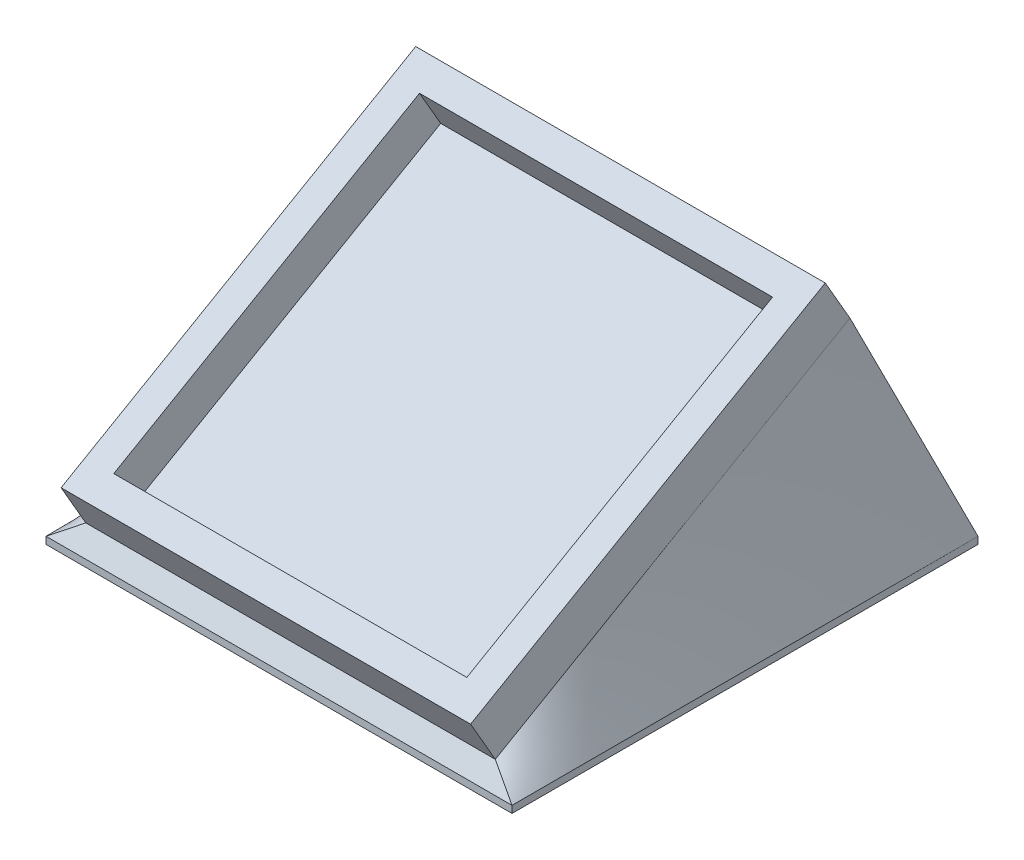
from build123d import *

# Parameters (mm, degrees)
SKETCH1_W             = 36.83
SKETCH1_H             = 36.83
BOSS_EXTRUDE1_DEPTH   = 0.635
SKETCH2_W             = 36.83
SKETCH2_H             = 36.83
SKETCH2_W_2           = 31.75
SKETCH2_H_2           = 31.75
BOSS_EXTRUDE2_DEPTH   = 3.81
SKETCH3_W             = 41.91
SKETCH3_H             = 41.91
BOSS_EXTRUDE3_DEPTH   = 0.635
BODY_MOVE_COPY2_ANGLE = 30
CUT_EXTRUDE1_DEPTH    = 0.635


with BuildPart() as part:
    # Sketch1 → Boss-Extrude1 (new body)
    with BuildSketch(Plane(origin=(0, 0, 0), x_dir=(1, 0, 0), z_dir=(0, 1, 0))):
        with Locations((-3.873751075, -5.413720286)):
            Rectangle(SKETCH1_W, SKETCH1_H)
    extrude(amount=BOSS_EXTRUDE1_DEPTH)

    # Sketch2 → Boss-Extrude2 (add)
    with BuildSketch(Plane(origin=(0, 0.635, 0), x_dir=(1, 0, 0), z_dir=(0, 1, 0))):
        with Locations((-3.873751075, -5.413720286)):
            Rectangle(SKETCH2_W, SKETCH2_H)
        with Locations((-3.873751075, -5.413720286)):
            Rectangle(SKETCH2_W_2, SKETCH2_H_2, mode=Mode.SUBTRACT)
    extrude(amount=BOSS_EXTRUDE2_DEPTH)


with BuildPart() as part_1:
    # Body-Move/Copy1: moved
    add(part.part.moved(Location((0, 12.7, 0))))


with BuildPart() as body_2:
    # Sketch3 → Boss-Extrude3 (new body)
    with BuildSketch(Plane(origin=(0, 0, 0), x_dir=(1, 0, 0), z_dir=(0, 1, 0))):
        with Locations((-3.873751075, -5.413720286)):
            Rectangle(SKETCH3_W, SKETCH3_H)
    extrude(amount=BOSS_EXTRUDE3_DEPTH)


with BuildPart() as part_2:
    # Body-Move/Copy2: moved
    add(part_1.part.moved(Location((0, 0, 0))).rotate(Axis((0, 4.7625, 5.413720286), (1, 0, 0)), BODY_MOVE_COPY2_ANGLE))


    add(body_2.part)  # loft1 joins it to this body
    # loft from a face of the part (loft1)
    loft([part_2.faces().sort_by_distance((-3.873751075, 11.636576643, 9.382470286))[0], part_2.faces().sort_by_distance((-3.873751075, 0.635, 5.413720286))[0]])

    # Sketch4 → Cut-Extrude1 (cut)
    with BuildSketch(Plane(origin=(0, 8.053915352, -13.949790589), x_dir=(1, 0, 0), z_dir=(0, 0.5000000000000009, -0.8660254037844382))):
        with BuildLine():
            Line((13.957915592, -17.461113821), (14.272018156, -17.461113821))
            add(Edge.make_bspline(
                [(14.272018156, -17.461113821), (14.263508605, -17.496346305), (14.246873129, -17.565222929), (14.212175556, -17.66363019), (14.174376301, -17.756753711), (14.128987196, -17.842849785), (14.079478442, -17.923648688), (14.02275572, -17.997317812), (13.961435998, -18.065730778), (13.893611049, -18.126444015), (13.822482387, -18.181421744), (13.747047767, -18.228296802), (13.668824874, -18.268620955), (13.587271741, -18.301841187), (13.502145569, -18.32686671), (13.414215946, -18.345023516), (13.323252445, -18.35681463), (13.261504855, -18.357965393), (13.230151168, -18.358549718)],
                knots=[0, 0, 0, 0, 1.162005537, 2.271625781, 3.343758855, 4.383309926, 5.390229558, 6.379919256, 7.361854164, 8.333198761, 9.295911338, 10.242430842, 11.177959212, 12.116337295, 13.062827104, 14.020064771, 14.994644689, 16, 16, 16, 16], degree=3))
            add(Edge.make_bspline(
                [(13.230151168, -18.358549718), (13.184468426, -18.357170488), (13.094099415, -18.354442112), (12.961336369, -18.329527676), (12.833309549, -18.290102544), (12.711420302, -18.235628816), (12.598201869, -18.168441503), (12.497465682, -18.088476766), (12.410577171, -17.997277465), (12.337682794, -17.896544901), (12.280607795, -17.788889391), (12.238521421, -17.678089234), (12.21289974, -17.564407263), (12.209579183, -17.487649984), (12.207915592, -17.44919475)],
                knots=[0, 0, 0, 0, 1.083050992, 2.142477498, 3.193116406, 4.255571735, 5.30263384, 6.308962982, 7.297363603, 8.282367274, 9.249857812, 10.179914175, 11.08814088, 12, 12, 12, 12], degree=3))
            add(Edge.make_bspline(
                [(12.207915592, -17.44919475), (12.209079183, -17.412187956), (12.21135615, -17.339771401), (12.230689855, -17.234049904), (12.263226118, -17.134408304), (12.308295881, -17.040427142), (12.366637431, -16.952702302), (12.437310128, -16.871036411), (12.52081279, -16.795067253), (12.584091728, -16.75154778), (12.616669598, -16.729142667)],
                knots=[0, 0, 0, 0, 1.024540389, 2.004866551, 2.965041327, 3.920577974, 4.882998113, 5.874504559, 6.905732034, 8, 8, 8, 8], degree=3))
            add(Edge.make_bspline(
                [(12.616669598, -16.729142667), (12.579390387, -16.711229669), (12.505409784, -16.675681323), (12.405588362, -16.604857863), (12.313589876, -16.525093068), (12.262887093, -16.462150715), (12.237362707, -16.430464782)],
                knots=[0, 0, 0, 0, 1.015663554, 2.015584519, 3.001021554, 4, 4, 4, 4], degree=3))
            add(Edge.make_bspline(
                [(12.237362707, -16.430464782), (12.220514509, -16.407409488), (12.187094015, -16.361676446), (12.145958634, -16.28810412), (12.10821415, -16.213959889), (12.080435303, -16.136328496), (12.056463258, -16.057703598), (12.040690451, -15.976401523), (12.03056494, -15.893194709), (12.029143111, -15.836878004), (12.028428412, -15.80856975)],
                knots=[0, 0, 0, 0, 1.02516404, 2.033540309, 3.025129118, 4.011046665, 4.991655828, 5.976607087, 6.982917762, 8, 8, 8, 8], degree=3))
            add(Edge.make_bspline(
                [(12.028428412, -15.80856975), (12.030227135, -15.759562229), (12.033816116, -15.661777817), (12.06575705, -15.517270095), (12.115580867, -15.376274036), (12.185018616, -15.240789231), (12.271319226, -15.114411971), (12.373424588, -15.001013205), (12.491443421, -14.904427957), (12.621939528, -14.823012609), (12.763865991, -14.758491863), (12.915064337, -14.711999437), (13.074639366, -14.684110502), (13.183765511, -14.680764351), (13.239265752, -14.679062539)],
                knots=[0, 0, 0, 0, 0.955619592, 1.906742024, 2.874954321, 3.868585453, 4.869520953, 5.854611167, 6.836527075, 7.836578462, 8.849204403, 9.870874567, 10.917152508, 12, 12, 12, 12], degree=3))
            add(Edge.make_bspline(
                [(13.239265752, -14.679062539), (13.276682697, -14.679938325), (13.350306767, -14.681661579), (13.45858381, -14.693232333), (13.561720295, -14.714939913), (13.660717716, -14.742240199), (13.754081962, -14.779985903), (13.843155991, -14.824985775), (13.927549361, -14.878393777), (14.006760886, -14.940299727), (14.08070594, -15.00959418), (14.147500647, -15.087428311), (14.20788402, -15.172349467), (14.26147239, -15.265121525), (14.30849129, -15.365484646), (14.34792887, -15.473841002), (14.382362748, -15.589350567), (14.398403477, -15.669824717), (14.40663354, -15.711113821)],
                knots=[0, 0, 0, 0, 1.048603596, 2.063302207, 3.045874044, 3.999447474, 4.937100059, 5.862643889, 6.7929026, 7.7308982, 8.676022965, 9.627908155, 10.600123445, 11.591992905, 12.626222643, 13.701663232, 14.820785756, 16, 16, 16, 16], degree=3))
            Line((14.40663354, -15.711113821), (14.092530976, -15.711113821))
            add(Edge.make_bspline(
                [(14.092530976, -15.711113821), (14.084347685, -15.684164807), (14.068430472, -15.631746636), (14.041336174, -15.55630633), (14.010467902, -15.487148277), (13.977353343, -15.423765155), (13.942574897, -15.365532753), (13.903659972, -15.313990883), (13.863490827, -15.266875681), (13.833211474, -15.240331069), (13.818392354, -15.227339782)],
                knots=[0, 0, 0, 0, 1.198163088, 2.33053128, 3.407730985, 4.417276592, 5.372219308, 6.28897303, 7.162600585, 8, 8, 8, 8], degree=3))
            add(Edge.make_bspline(
                [(13.818392354, -15.227339782), (13.798793589, -15.212237678), (13.759656555, -15.182080087), (13.695921174, -15.14348496), (13.628656555, -15.110448455), (13.557301761, -15.083594998), (13.481847218, -15.063437826), (13.402599002, -15.048929641), (13.319427086, -15.039351985), (13.262663879, -15.038481654), (13.233656777, -15.038036898)],
                knots=[0, 0, 0, 0, 0.946083416, 1.889246487, 2.84504177, 3.809995578, 4.801312957, 5.829064617, 6.89060985, 8, 8, 8, 8], degree=3))
            add(Edge.make_bspline(
                [(13.233656777, -15.038036898), (13.200902831, -15.038651801), (13.136855318, -15.039854192), (13.043406653, -15.050943893), (12.954477073, -15.067024305), (12.870974104, -15.092177196), (12.791761476, -15.122352244), (12.718607443, -15.161856919), (12.649361368, -15.206471064), (12.586051839, -15.258365895), (12.528975204, -15.314458589), (12.479654685, -15.37396794), (12.436937474, -15.435048768), (12.402599966, -15.499125968), (12.375437385, -15.565570992), (12.356957396, -15.634632545), (12.344105026, -15.705729086), (12.34305853, -15.754058153), (12.342530976, -15.778421513)],
                knots=[0, 0, 0, 0, 1.216990249, 2.379719373, 3.493992396, 4.571561497, 5.616923107, 6.638958652, 7.655775068, 8.674704564, 9.676001865, 10.625896028, 11.54399481, 12.441854662, 13.322657739, 14.20572845, 15.095482574, 16, 16, 16, 16], degree=3))
            add(Edge.make_bspline(
                [(12.342530976, -15.778421513), (12.344064471, -15.811030803), (12.347123829, -15.876087124), (12.370384583, -15.971835387), (12.408987376, -16.064124126), (12.461978856, -16.151744741), (12.528031816, -16.232002064), (12.604023935, -16.30384102), (12.691576646, -16.363658005), (12.772616319, -16.404871124), (12.844585224, -16.432329798), (12.90605032, -16.451584674), (12.974923873, -16.466976302), (13.050378314, -16.481864776), (13.132732104, -16.494346291), (13.222059369, -16.50480006), (13.318396067, -16.513151574), (13.385087098, -16.516883175), (13.419454053, -16.518806128)],
                knots=[0, 0, 0, 0, 1.070440979, 2.135555593, 3.216243406, 4.345886539, 5.486149072, 6.621334998, 7.769144672, 8.957074012, 9.598644492, 10.297969361, 11.070758978, 11.915404831, 12.824182859, 13.805940418, 14.869366021, 16, 16, 16, 16], degree=3))
            Line((13.419454053, -16.518806128), (13.419454053, -16.877780487))
            add(Edge.make_bspline(
                [(13.419454053, -16.877780487), (13.376169728, -16.878624389), (13.291416017, -16.880276808), (13.167264497, -16.896146899), (13.048909301, -16.921906298), (12.938130667, -16.957869767), (12.837682173, -17.001652447), (12.749703548, -17.050672324), (12.67735984, -17.107224535), (12.619355367, -17.168635777), (12.57633282, -17.234919002), (12.544576117, -17.303689517), (12.525792697, -17.376226691), (12.523280766, -17.425719603), (12.522018156, -17.450596994)],
                knots=[0, 0, 0, 0, 1.321816535, 2.58820849, 3.816448615, 5.017641336, 6.139869627, 7.160068286, 8.085608132, 8.934319198, 9.728416342, 10.48890201, 11.240453369, 12, 12, 12, 12], degree=3))
            add(Edge.make_bspline(
                [(12.522018156, -17.450596994), (12.522423449, -17.468877824), (12.523229761, -17.505246669), (12.533804515, -17.558546665), (12.548960859, -17.610217994), (12.570979956, -17.65965691), (12.599457343, -17.707020575), (12.633910742, -17.752481977), (12.674427426, -17.796475232), (12.720744289, -17.83803007), (12.772435095, -17.87543016), (12.827425176, -17.908771819), (12.885928917, -17.936807408), (12.947565065, -17.960047007), (13.012666792, -17.977498008), (13.080891614, -17.990036171), (13.15237978, -17.99787318), (13.201151445, -17.999001685), (13.225944438, -17.999575359)],
                knots=[0, 0, 0, 0, 0.884246871, 1.759167212, 2.622361933, 3.489113179, 4.372562419, 5.294145153, 6.247651513, 7.265905295, 8.30305477, 9.334068495, 10.37719476, 11.441246459, 12.52060732, 13.637552802, 14.799054011, 16, 16, 16, 16], degree=3))
            add(Edge.make_bspline(
                [(13.225944438, -17.999575359), (13.265797423, -17.998186696), (13.343639571, -17.995474314), (13.45583614, -17.971633698), (13.560030367, -17.933860699), (13.639405351, -17.888249916), (13.698118095, -17.843381124), (13.740878067, -17.804780502), (13.782103059, -17.761015303), (13.820175367, -17.710885096), (13.857376363, -17.656113657), (13.893350833, -17.596399325), (13.926943277, -17.530890753), (13.947391548, -17.484823236), (13.957915592, -17.461113821)],
                knots=[0, 0, 0, 0, 1.4727372, 2.876598283, 4.222346151, 5.558423782, 6.24313385, 6.953189256, 7.68715613, 8.463578749, 9.278833271, 10.135787152, 11.040551781, 12, 12, 12, 12], degree=3))
        make_face()
        with BuildLine():
            add(Edge.make_bspline(
                [(11.714325848, -16.517403885), (11.71399783, -16.573501273), (11.71336065, -16.682471257), (11.706272229, -16.841255899), (11.694496887, -16.990216189), (11.678359511, -17.129359252), (11.658721542, -17.258721026), (11.632506019, -17.377955749), (11.602693338, -17.487615471), (11.568140482, -17.588057131), (11.529154106, -17.680636173), (11.486714862, -17.767056651), (11.439167739, -17.847215331), (11.389127652, -17.922293251), (11.334843292, -17.991534852), (11.276503433, -18.054628948), (11.214621937, -18.112553276), (11.148905998, -18.164355346), (11.079981971, -18.209493939), (11.009888719, -18.250411053), (10.936627038, -18.282777619), (10.862003968, -18.31045476), (10.785418288, -18.332378797), (10.706836635, -18.347628686), (10.626188492, -18.35716934), (10.571757983, -18.358085227), (10.544153572, -18.358549718)],
                knots=[0, 0, 0, 0, 1.64625301, 3.197870201, 4.6634513, 6.030635694, 7.308242971, 8.501545196, 9.611429483, 10.641742253, 11.616230371, 12.55791849, 13.464870342, 14.34944951, 15.20427819, 16.044004467, 16.869007726, 17.689551165, 18.496129964, 19.285613293, 20.0683943, 20.843080271, 21.620342827, 22.403213977, 23.190190624, 24, 24, 24, 24], degree=3))
            add(Edge.make_bspline(
                [(10.544153572, -18.358549718), (10.516304595, -18.358163468), (10.460894931, -18.357394967), (10.379269782, -18.346577848), (10.299066405, -18.33261588), (10.221501642, -18.310223182), (10.145108893, -18.283427415), (10.071787892, -18.248070826), (9.998950021, -18.20961779), (9.929904205, -18.16270832), (9.862587484, -18.110865637), (9.799485085, -18.052010938), (9.738983945, -17.987773033), (9.683369166, -17.916719229), (9.630257177, -17.839938992), (9.581664162, -17.756788682), (9.536579476, -17.667452571), (9.494155646, -17.57234481), (9.457057127, -17.468924921), (9.424073578, -17.357837963), (9.397037979, -17.238077988), (9.374680014, -17.110312137), (9.357325977, -16.973907459), (9.344696002, -16.829140325), (9.338022158, -16.675920167), (9.336765564, -16.571162285), (9.33612072, -16.517403885)],
                knots=[0, 0, 0, 0, 0.810910589, 1.61342667, 2.396193133, 3.181089899, 3.963115317, 4.752255436, 5.550715454, 6.36105385, 7.181178335, 8.024612154, 8.872680183, 9.750181803, 10.651284446, 11.591556747, 12.554036451, 13.566402641, 14.62422919, 15.753422176, 16.94128843, 18.199818041, 19.531985927, 20.947085226, 22.433341622, 24, 24, 24, 24], degree=3))
            add(Edge.make_bspline(
                [(9.33612072, -16.517403885), (9.336780554, -16.463880645), (9.338069091, -16.35935935), (9.344544115, -16.206818664), (9.357664545, -16.062841488), (9.373655976, -15.927219225), (9.396712493, -15.800129158), (9.422381285, -15.680888765), (9.45512327, -15.570618452), (9.49134182, -15.468085055), (9.533175351, -15.373380178), (9.577920496, -15.284412818), (9.627238893, -15.201734405), (9.679331761, -15.124467495), (9.735999438, -15.054023067), (9.795681818, -14.989066583), (9.859396408, -14.930109631), (9.927059658, -14.877654826), (9.996758081, -14.830391991), (10.069610152, -14.790567837), (10.143910473, -14.755849301), (10.220431861, -14.727939658), (10.298686364, -14.705876975), (10.378955788, -14.690857918), (10.460905847, -14.680271374), (10.516308246, -14.679466879), (10.544153572, -14.679062539)],
                knots=[0, 0, 0, 0, 1.561431216, 3.049195289, 4.452146966, 5.778046447, 7.031138842, 8.218704273, 9.334037798, 10.384210803, 11.388620812, 12.352076869, 13.287433199, 14.19507451, 15.06813243, 15.922055533, 16.766344942, 17.596869952, 18.417486629, 19.220035357, 20.016159057, 20.807716045, 21.59340902, 22.384936649, 23.188266813, 24, 24, 24, 24], degree=3))
            add(Edge.make_bspline(
                [(10.544153572, -14.679062539), (10.571757021, -14.679531147), (10.626185633, -14.68045515), (10.706847672, -14.689936345), (10.785315386, -14.705396978), (10.861745643, -14.726392439), (10.936294839, -14.753076436), (11.008232764, -14.787017451), (11.078509198, -14.826383898), (11.1468045, -14.871170029), (11.211813068, -14.922495946), (11.273922429, -14.979252656), (11.331506913, -15.042902841), (11.385416908, -15.112430595), (11.435872191, -15.187697512), (11.483217966, -15.268469849), (11.525527968, -15.355732211), (11.565398314, -15.448813825), (11.600544328, -15.549993504), (11.631233179, -15.660029014), (11.657106673, -15.7796709), (11.677715271, -15.908924888), (11.69459831, -16.047590886), (11.70626062, -16.195889864), (11.713357106, -16.353504179), (11.713997041, -16.461773686), (11.714325848, -16.517403885)],
                knots=[0, 0, 0, 0, 0.810976328, 1.599087026, 2.383086309, 3.159618043, 3.926613167, 4.707144544, 5.494386734, 6.292609454, 7.104690378, 7.92621526, 8.762510248, 9.62398222, 10.509836085, 11.424023232, 12.373226806, 13.358118208, 14.398657954, 15.5185989, 16.713620699, 17.994156382, 19.364120462, 20.818119981, 22.365111093, 24, 24, 24, 24], degree=3))
        make_face()
        with BuildLine():
            add(Edge.make_bspline(
                [(11.400223284, -16.518806128), (11.400101218, -16.472057617), (11.399864311, -16.381327934), (11.393854403, -16.249715111), (11.385489226, -16.126753577), (11.374965347, -16.012491328), (11.359204356, -15.907327693), (11.341322506, -15.810825516), (11.319874458, -15.723163264), (11.294371978, -15.643575389), (11.265323705, -15.57093316), (11.233658511, -15.503306404), (11.199358263, -15.439872541), (11.16163601, -15.380860441), (11.1199513, -15.326599699), (11.075234552, -15.276832616), (11.027225749, -15.231761827), (10.960781663, -15.178271933), (10.873489802, -15.122346323), (10.762943389, -15.074244984), (10.649301897, -15.043820973), (10.572147097, -15.039962688), (10.533636745, -15.038036898)],
                knots=[0, 0, 0, 0, 1.459193451, 2.832007961, 4.111736495, 5.306635028, 6.412683014, 7.430020708, 8.369596877, 9.227877302, 10.036669781, 10.810175692, 11.557788084, 12.286326232, 12.994037279, 13.69140682, 14.37267704, 15.047194847, 16.352618509, 17.594157723, 18.799169539, 20, 20, 20, 20], degree=3))
            add(Edge.make_bspline(
                [(10.533636745, -15.038036898), (10.494905261, -15.039725552), (10.41757968, -15.043096869), (10.304015539, -15.072520403), (10.194679052, -15.120353725), (10.108391856, -15.175002161), (10.042928257, -15.227378854), (9.996007362, -15.271983534), (9.952946399, -15.321942172), (9.912104023, -15.375840698), (9.874645031, -15.434713396), (9.84058187, -15.498275911), (9.809498529, -15.566705105), (9.791789482, -15.614474842), (9.782735303, -15.638898276)],
                knots=[0, 0, 0, 0, 1.353621445, 2.702441307, 4.075953605, 5.516772412, 6.261413105, 7.007624062, 7.778524365, 8.566925914, 9.372323995, 10.217594641, 11.088702136, 12, 12, 12, 12], degree=3))
            add(Edge.make_bspline(
                [(9.782735303, -15.638898276), (9.772183535, -15.670128015), (9.750758921, -15.73353778), (9.723147147, -15.831901432), (9.701401748, -15.935104196), (9.681838382, -16.042529312), (9.668485326, -16.154969013), (9.657737513, -16.272075397), (9.651406826, -16.393936759), (9.650622075, -16.476731751), (9.650223284, -16.518806128)],
                knots=[0, 0, 0, 0, 0.884706709, 1.796334032, 2.740027952, 3.714592787, 4.726048262, 5.777819803, 6.87074269, 8, 8, 8, 8], degree=3))
            add(Edge.make_bspline(
                [(9.650223284, -16.518806128), (9.650663108, -16.560879602), (9.651523604, -16.643194491), (9.657177142, -16.763621249), (9.666261908, -16.878200591), (9.67855794, -16.987036459), (9.695437789, -17.089935143), (9.715708817, -17.187043874), (9.739474236, -17.278336521), (9.766734006, -17.364048355), (9.797454951, -17.443871873), (9.831393895, -17.517978905), (9.867606121, -17.586769147), (9.906963741, -17.650021339), (9.948909912, -17.70810456), (9.994950772, -17.759681773), (10.042161843, -17.807262063), (10.109305977, -17.860603074), (10.196494665, -17.91541977), (10.305735224, -17.964493159), (10.418794492, -17.993536114), (10.495383596, -17.997563729), (10.533636745, -17.999575359)],
                knots=[0, 0, 0, 0, 1.313528337, 2.569860077, 3.762944266, 4.901481389, 5.988248151, 7.017139294, 7.997571128, 8.932104357, 9.823695246, 10.66607014, 11.475539426, 12.248954257, 12.990316782, 13.708962568, 14.405488541, 15.08007697, 16.381737273, 17.610043218, 18.806313575, 20, 20, 20, 20], degree=3))
            add(Edge.make_bspline(
                [(10.533636745, -17.999575359), (10.572354846, -17.997561349), (10.649861581, -17.993529659), (10.764103578, -17.964595627), (10.8739981, -17.915768796), (10.961003053, -17.860535289), (11.027201934, -17.807469217), (11.074310239, -17.762178446), (11.118768186, -17.712876789), (11.160253203, -17.658862067), (11.197745301, -17.599962493), (11.232462438, -17.536988488), (11.263874998, -17.469462189), (11.293032916, -17.396860109), (11.318264801, -17.317141456), (11.340951207, -17.229496687), (11.358461699, -17.132366914), (11.374009477, -17.026709431), (11.38576183, -16.912311332), (11.393796103, -16.789058719), (11.399882565, -16.656987102), (11.400107436, -16.565788979), (11.400223284, -16.518806128)],
                knots=[0, 0, 0, 0, 1.207779899, 2.417760083, 3.652287919, 4.947299644, 5.621638849, 6.297435916, 6.984320042, 7.691843698, 8.42018894, 9.161205785, 9.934506883, 10.743085206, 11.601138371, 12.542248028, 13.566483018, 14.679455109, 15.87477181, 17.154161492, 18.533899613, 20, 20, 20, 20], degree=3))
        make_face(mode=Mode.SUBTRACT)
        Polygon((7.67586431, -17.326498436), (7.302166393, -17.326498436), (6.643813027, -16.403822154), (5.985459662, -17.326498436), (5.611761745, -17.326498436), (6.456613508, -16.142303725), (5.477146361, -14.768806128), (5.850844277, -14.768806128), (6.643813027, -15.880084173), (7.436781777, -14.768806128), (7.810479694, -14.768806128), (6.830311425, -16.142303725), align=None)
        with BuildLine():
            add(Edge.make_bspline(
                [(3.99637713, -16.517403885), (3.996049112, -16.573501273), (3.995411932, -16.682471257), (3.988323511, -16.841255899), (3.976548169, -16.990216189), (3.960410793, -17.129359252), (3.940772824, -17.258721026), (3.914557301, -17.377955749), (3.88474462, -17.487615471), (3.850191764, -17.588057131), (3.811205388, -17.680636173), (3.768766144, -17.767056651), (3.721219021, -17.847215331), (3.671178934, -17.922293251), (3.616894574, -17.991534852), (3.558554715, -18.054628948), (3.496673219, -18.112553276), (3.43095728, -18.164355346), (3.362033253, -18.209493939), (3.291940001, -18.250411053), (3.21867832, -18.282777619), (3.14405525, -18.31045476), (3.06746957, -18.332378797), (2.988887917, -18.347628686), (2.908239774, -18.35716934), (2.853809265, -18.358085227), (2.826204854, -18.358549718)],
                knots=[0, 0, 0, 0, 1.64625301, 3.197870201, 4.6634513, 6.030635694, 7.308242971, 8.501545196, 9.611429483, 10.641742253, 11.616230371, 12.55791849, 13.464870342, 14.34944951, 15.20427819, 16.044004467, 16.869007726, 17.689551165, 18.496129964, 19.285613293, 20.0683943, 20.843080271, 21.620342827, 22.403213977, 23.190190624, 24, 24, 24, 24], degree=3))
            add(Edge.make_bspline(
                [(2.826204854, -18.358549718), (2.798355877, -18.358163468), (2.742946213, -18.357394967), (2.661321064, -18.346577848), (2.581117687, -18.33261588), (2.503552924, -18.310223182), (2.427160175, -18.283427415), (2.353839174, -18.248070826), (2.281001303, -18.20961779), (2.211955487, -18.16270832), (2.144638766, -18.110865637), (2.081536367, -18.052010938), (2.021035227, -17.987773033), (1.965420448, -17.916719229), (1.912308459, -17.839938992), (1.863715444, -17.756788682), (1.818630758, -17.667452571), (1.776206928, -17.57234481), (1.739108409, -17.468924921), (1.70612486, -17.357837963), (1.679089261, -17.238077988), (1.656731296, -17.110312137), (1.639377259, -16.973907459), (1.626747284, -16.829140325), (1.62007344, -16.675920167), (1.618816846, -16.571162285), (1.618172002, -16.517403885)],
                knots=[0, 0, 0, 0, 0.810910589, 1.61342667, 2.396193133, 3.181089899, 3.963115317, 4.752255436, 5.550715454, 6.36105385, 7.181178335, 8.024612154, 8.872680183, 9.750181803, 10.651284446, 11.591556747, 12.554036451, 13.566402641, 14.62422919, 15.753422176, 16.94128843, 18.199818041, 19.531985927, 20.947085226, 22.433341622, 24, 24, 24, 24], degree=3))
            add(Edge.make_bspline(
                [(1.618172002, -16.517403885), (1.618831836, -16.463880645), (1.620120373, -16.35935935), (1.626595397, -16.206818664), (1.639715827, -16.062841488), (1.655707259, -15.927219225), (1.678763775, -15.800129158), (1.704432567, -15.680888765), (1.737174552, -15.570618452), (1.773393102, -15.468085055), (1.815226633, -15.373380178), (1.859971778, -15.284412818), (1.909290175, -15.201734405), (1.961383043, -15.124467495), (2.01805072, -15.054023067), (2.0777331, -14.989066583), (2.14144769, -14.930109631), (2.20911094, -14.877654826), (2.278809363, -14.830391991), (2.351661434, -14.790567837), (2.425961755, -14.755849301), (2.502483143, -14.727939658), (2.580737646, -14.705876975), (2.66100707, -14.690857918), (2.742957129, -14.680271374), (2.798359528, -14.679466879), (2.826204854, -14.679062539)],
                knots=[0, 0, 0, 0, 1.561431216, 3.049195289, 4.452146966, 5.778046447, 7.031138842, 8.218704273, 9.334037798, 10.384210803, 11.388620812, 12.352076869, 13.287433199, 14.19507451, 15.06813243, 15.922055533, 16.766344942, 17.596869952, 18.417486629, 19.220035357, 20.016159057, 20.807716045, 21.59340902, 22.384936649, 23.188266813, 24, 24, 24, 24], degree=3))
            add(Edge.make_bspline(
                [(2.826204854, -14.679062539), (2.853808303, -14.679531147), (2.908236915, -14.68045515), (2.988898954, -14.689936345), (3.067366668, -14.705396978), (3.143796925, -14.726392439), (3.218346121, -14.753076436), (3.290284046, -14.787017451), (3.36056048, -14.826383898), (3.428855782, -14.871170029), (3.49386435, -14.922495946), (3.555973711, -14.979252656), (3.613558195, -15.042902841), (3.66746819, -15.112430595), (3.717923473, -15.187697512), (3.765269248, -15.268469849), (3.80757925, -15.355732211), (3.847449596, -15.448813825), (3.88259561, -15.549993504), (3.913284461, -15.660029014), (3.939157955, -15.7796709), (3.959766553, -15.908924888), (3.976649592, -16.047590886), (3.988311902, -16.195889864), (3.995408388, -16.353504179), (3.996048323, -16.461773686), (3.99637713, -16.517403885)],
                knots=[0, 0, 0, 0, 0.810976328, 1.599087026, 2.383086309, 3.159618043, 3.926613167, 4.707144544, 5.494386734, 6.292609454, 7.104690378, 7.92621526, 8.762510248, 9.62398222, 10.509836085, 11.424023232, 12.373226806, 13.358118208, 14.398657954, 15.5185989, 16.713620699, 17.994156382, 19.364120462, 20.818119981, 22.365111093, 24, 24, 24, 24], degree=3))
        make_face()
        with BuildLine():
            add(Edge.make_bspline(
                [(3.682274566, -16.518806128), (3.6821525, -16.472057617), (3.681915593, -16.381327934), (3.675905685, -16.249715111), (3.667540508, -16.126753577), (3.657016629, -16.012491328), (3.641255638, -15.907327693), (3.623373788, -15.810825516), (3.60192574, -15.723163264), (3.57642326, -15.643575389), (3.547374987, -15.57093316), (3.515709793, -15.503306404), (3.481409545, -15.439872541), (3.443687292, -15.380860441), (3.402002582, -15.326599699), (3.357285834, -15.276832616), (3.309277031, -15.231761827), (3.242832945, -15.178271933), (3.155541084, -15.122346323), (3.044994671, -15.074244984), (2.931353179, -15.043820973), (2.85419838, -15.039962688), (2.815688027, -15.038036898)],
                knots=[0, 0, 0, 0, 1.459193451, 2.832007961, 4.111736495, 5.306635028, 6.412683014, 7.430020708, 8.369596877, 9.227877302, 10.036669781, 10.810175692, 11.557788084, 12.286326232, 12.994037279, 13.69140682, 14.37267704, 15.047194847, 16.352618509, 17.594157723, 18.799169539, 20, 20, 20, 20], degree=3))
            add(Edge.make_bspline(
                [(2.815688027, -15.038036898), (2.776956543, -15.039725552), (2.699630962, -15.043096869), (2.586066821, -15.072520403), (2.476730334, -15.120353725), (2.390443138, -15.175002161), (2.324979539, -15.227378854), (2.278058644, -15.271983534), (2.234997681, -15.321942172), (2.194155305, -15.375840698), (2.156696313, -15.434713396), (2.122633152, -15.498275911), (2.091549811, -15.566705105), (2.073840764, -15.614474842), (2.064786585, -15.638898276)],
                knots=[0, 0, 0, 0, 1.353621445, 2.702441307, 4.075953605, 5.516772412, 6.261413105, 7.007624062, 7.778524365, 8.566925914, 9.372323995, 10.217594641, 11.088702136, 12, 12, 12, 12], degree=3))
            add(Edge.make_bspline(
                [(2.064786585, -15.638898276), (2.054234817, -15.670128015), (2.032810204, -15.73353778), (2.005198429, -15.831901432), (1.98345303, -15.935104196), (1.963889664, -16.042529312), (1.950536608, -16.154969013), (1.939788795, -16.272075397), (1.933458108, -16.393936759), (1.932673357, -16.476731751), (1.932274566, -16.518806128)],
                knots=[0, 0, 0, 0, 0.884706709, 1.796334032, 2.740027952, 3.714592787, 4.726048262, 5.777819803, 6.87074269, 8, 8, 8, 8], degree=3))
            add(Edge.make_bspline(
                [(1.932274566, -16.518806128), (1.93271439, -16.560879602), (1.933574886, -16.643194491), (1.939228424, -16.763621249), (1.94831319, -16.878200591), (1.960609222, -16.987036459), (1.977489071, -17.089935143), (1.997760099, -17.187043874), (2.021525518, -17.278336521), (2.048785288, -17.364048355), (2.079506233, -17.443871873), (2.113445177, -17.517978905), (2.149657403, -17.586769147), (2.189015023, -17.650021339), (2.230961194, -17.70810456), (2.277002054, -17.759681773), (2.324213125, -17.807262063), (2.391357259, -17.860603074), (2.478545947, -17.91541977), (2.587786506, -17.964493159), (2.700845774, -17.993536114), (2.777434878, -17.997563729), (2.815688027, -17.999575359)],
                knots=[0, 0, 0, 0, 1.313528337, 2.569860077, 3.762944266, 4.901481389, 5.988248151, 7.017139294, 7.997571128, 8.932104357, 9.823695246, 10.66607014, 11.475539426, 12.248954257, 12.990316782, 13.708962568, 14.405488541, 15.08007697, 16.381737273, 17.610043218, 18.806313575, 20, 20, 20, 20], degree=3))
            add(Edge.make_bspline(
                [(2.815688027, -17.999575359), (2.854406128, -17.997561349), (2.931912863, -17.993529659), (3.04615486, -17.964595627), (3.156049382, -17.915768796), (3.243054335, -17.860535289), (3.309253216, -17.807469217), (3.356361521, -17.762178446), (3.400819468, -17.712876789), (3.442304485, -17.658862067), (3.479796583, -17.599962493), (3.51451372, -17.536988488), (3.54592628, -17.469462189), (3.575084198, -17.396860109), (3.600316083, -17.317141456), (3.623002489, -17.229496687), (3.640512981, -17.132366914), (3.656060759, -17.026709431), (3.667813112, -16.912311332), (3.675847385, -16.789058719), (3.681933847, -16.656987102), (3.682158718, -16.565788979), (3.682274566, -16.518806128)],
                knots=[0, 0, 0, 0, 1.207779899, 2.417760083, 3.652287919, 4.947299644, 5.621638849, 6.297435916, 6.984320042, 7.691843698, 8.42018894, 9.161205785, 9.934506883, 10.743085206, 11.601138371, 12.542248028, 13.566483018, 14.679455109, 15.87477181, 17.154161492, 18.533899613, 20, 20, 20, 20], degree=3))
        make_face(mode=Mode.SUBTRACT)
    extrude(amount=-CUT_EXTRUDE1_DEPTH, mode=Mode.SUBTRACT)


solid = part_2.part
